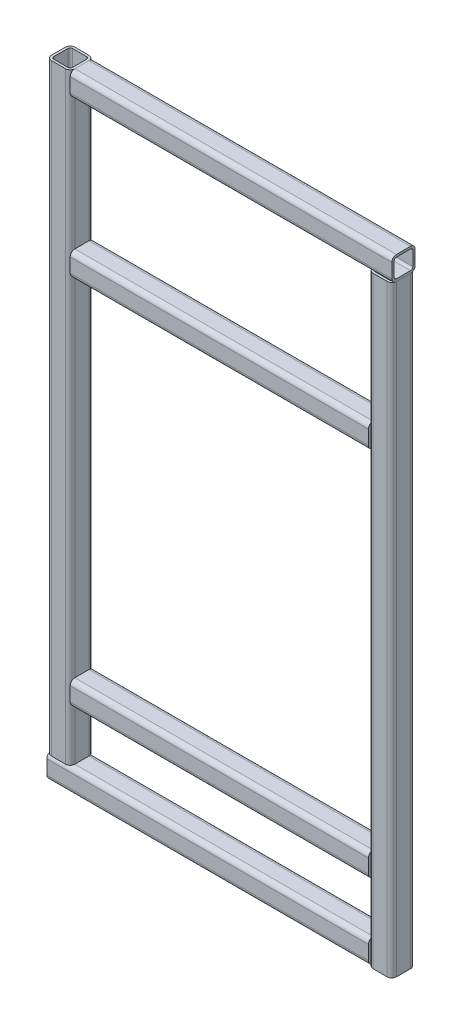
from build123d import *

# Parameters (mm, degrees)
SQUARE_TUBE_20_X_20_X_2_1_DEPTH      = 285
SQUARE_TUBE_20_X_20_X_2_1_DEPTH_BACK = 1
SQUARE_TUBE_20_X_20_X_2_1_2_DEPTH    = 526
SQUARE_TUBE_20_X_20_X_2_1_3_DEPTH    = 286
SQUARE_TUBE_20_X_20_X_2_1_4_DEPTH    = 526
SQUARE_TUBE_20_X_20_X_2_1_5_DEPTH    = 277
SQUARE_TUBE_20_X_20_X_2_1_6_DEPTH    = 277
SKETCH17_R                           = 2.5
CUT_EXTRUDE1_DEPTH                   = 5


with BuildPart() as part:
    # Sketch16 → Square tube 20 X 20 X 2(1) (new, two sides)
    with BuildSketch(Plane(origin=(-137.5, 257.5, 0), x_dir=(0, 1, 0), z_dir=(1, 0, 0))) as square_tube_20_x_20_x_2_1_sk:
        with BuildLine():
            Line((-6, -10), (6, -10))
            ThreePointArc((6, -10), (8.828427125, -8.828427125), (10, -6))
            Line((10, -6), (10, 6))
            ThreePointArc((10, 6), (8.828427125, 8.828427125), (6, 10))
            Line((6, 10), (-6, 10))
            ThreePointArc((-6, 10), (-8.828427125, 8.828427125), (-10, 6))
            Line((-10, 6), (-10, -6))
            ThreePointArc((-10, -6), (-8.828427125, -8.828427125), (-6, -10))
        make_face()
        with BuildLine():
            Line((-6, -8), (6, -8))
            ThreePointArc((6, -8), (7.414213562, -7.414213562), (8, -6))
            Line((8, -6), (8, 6))
            ThreePointArc((8, 6), (7.414213562, 7.414213562), (6, 8))
            Line((6, 8), (-6, 8))
            ThreePointArc((-6, 8), (-7.414213562, 7.414213562), (-8, 6))
            Line((-8, 6), (-8, -6))
            ThreePointArc((-8, -6), (-7.414213562, -7.414213562), (-6, -8))
        make_face(mode=Mode.SUBTRACT)
    extrude(amount=SQUARE_TUBE_20_X_20_X_2_1_DEPTH)
    extrude(square_tube_20_x_20_x_2_1_sk.sketch, amount=-SQUARE_TUBE_20_X_20_X_2_1_DEPTH_BACK)

    # Square tube 20 X 20 X 2(1) end butt 1
    split(bisect_by=Plane(origin=(-127.5, 257.5, 0), x_dir=(0, 1, 0), z_dir=(1, 0, 0)), keep=Keep.TOP)


with BuildPart() as body_2:
    # Sketch16 on segment 2 (carried to segment 2) → Square tube 20 X 20 X 2_1 2 (new body)
    with BuildSketch(Plane(origin=(137.5, 258.5, 0), x_dir=(1, 0, 0), z_dir=(0, -1, 0))):
        with BuildLine():
            Line((-6, -10), (6, -10))
            ThreePointArc((6, -10), (8.828427125, -8.828427125), (10, -6))
            Line((10, -6), (10, 6))
            ThreePointArc((10, 6), (8.828427125, 8.828427125), (6, 10))
            Line((6, 10), (-6, 10))
            ThreePointArc((-6, 10), (-8.828427125, 8.828427125), (-10, 6))
            Line((-10, 6), (-10, -6))
            ThreePointArc((-10, -6), (-8.828427125, -8.828427125), (-6, -10))
        make_face()
        with BuildLine():
            Line((-6, -8), (6, -8))
            ThreePointArc((6, -8), (7.414213562, -7.414213562), (8, -6))
            Line((8, -6), (8, 6))
            ThreePointArc((8, 6), (7.414213562, 7.414213562), (6, 8))
            Line((6, 8), (-6, 8))
            ThreePointArc((-6, 8), (-7.414213562, 7.414213562), (-8, 6))
            Line((-8, 6), (-8, -6))
            ThreePointArc((-8, -6), (-7.414213562, -7.414213562), (-6, -8))
        make_face(mode=Mode.SUBTRACT)
    extrude(amount=SQUARE_TUBE_20_X_20_X_2_1_2_DEPTH)

    # Square tube 20 X 20 X 2_1 2 end butt 1
    split(bisect_by=Plane(origin=(137.5, 247.5, 0), x_dir=(1, 0, 0), z_dir=(0, -1, 0)), keep=Keep.TOP)


with BuildPart() as body_3:
    # Sketch16 on segment 3 (carried to segment 3) → Square tube 20 X 20 X 2_1 3 (new body)
    with BuildSketch(Plane(origin=(138.5, -257.5, 0), x_dir=(0, -1, 0), z_dir=(-1, 0, 0))):
        with BuildLine():
            Line((-6, -10), (6, -10))
            ThreePointArc((6, -10), (8.828427125, -8.828427125), (10, -6))
            Line((10, -6), (10, 6))
            ThreePointArc((10, 6), (8.828427125, 8.828427125), (6, 10))
            Line((6, 10), (-6, 10))
            ThreePointArc((-6, 10), (-8.828427125, 8.828427125), (-10, 6))
            Line((-10, 6), (-10, -6))
            ThreePointArc((-10, -6), (-8.828427125, -8.828427125), (-6, -10))
        make_face()
        with BuildLine():
            Line((-6, -8), (6, -8))
            ThreePointArc((6, -8), (7.414213562, -7.414213562), (8, -6))
            Line((8, -6), (8, 6))
            ThreePointArc((8, 6), (7.414213562, 7.414213562), (6, 8))
            Line((6, 8), (-6, 8))
            ThreePointArc((-6, 8), (-7.414213562, 7.414213562), (-8, 6))
            Line((-8, 6), (-8, -6))
            ThreePointArc((-8, -6), (-7.414213562, -7.414213562), (-6, -8))
        make_face(mode=Mode.SUBTRACT)
    extrude(amount=SQUARE_TUBE_20_X_20_X_2_1_3_DEPTH)

    # Square tube 20 X 20 X 2_1 3 end butt 1
    split(bisect_by=Plane(origin=(127.5, -257.5, 0), x_dir=(0, -1, 0), z_dir=(-1, 0, 0)), keep=Keep.TOP)

    # Sketch17 → Cut-Extrude1 (cut)
    with BuildSketch(Plane(origin=(0, 0, -10), x_dir=(-1, 0, 0), z_dir=(0, 0, -1))):
        with Locations((35.5, -257.5)):
            Circle(SKETCH17_R)
        with Locations(Location((-35.5, -257.5, 0), (0, 0, 180))):
            Circle(SKETCH17_R)
    extrude(amount=-CUT_EXTRUDE1_DEPTH, mode=Mode.SUBTRACT)


with BuildPart() as body_4:
    # Sketch16 on segment 4 (carried to segment 4) → Square tube 20 X 20 X 2_1 4 (new body)
    with BuildSketch(Plane(origin=(-137.5, -258.5, 0), x_dir=(-1, 0, 0), z_dir=(0, 1, 0))):
        with BuildLine():
            Line((-6, -10), (6, -10))
            ThreePointArc((6, -10), (8.828427125, -8.828427125), (10, -6))
            Line((10, -6), (10, 6))
            ThreePointArc((10, 6), (8.828427125, 8.828427125), (6, 10))
            Line((6, 10), (-6, 10))
            ThreePointArc((-6, 10), (-8.828427125, 8.828427125), (-10, 6))
            Line((-10, 6), (-10, -6))
            ThreePointArc((-10, -6), (-8.828427125, -8.828427125), (-6, -10))
        make_face()
        with BuildLine():
            Line((-6, -8), (6, -8))
            ThreePointArc((6, -8), (7.414213562, -7.414213562), (8, -6))
            Line((8, -6), (8, 6))
            ThreePointArc((8, 6), (7.414213562, 7.414213562), (6, 8))
            Line((6, 8), (-6, 8))
            ThreePointArc((-6, 8), (-7.414213562, 7.414213562), (-8, 6))
            Line((-8, 6), (-8, -6))
            ThreePointArc((-8, -6), (-7.414213562, -7.414213562), (-6, -8))
        make_face(mode=Mode.SUBTRACT)
    extrude(amount=SQUARE_TUBE_20_X_20_X_2_1_4_DEPTH)

    # Square tube 20 X 20 X 2_1 4 end butt 1
    split(bisect_by=Plane(origin=(-137.5, -247.5, 0), x_dir=(-1, 0, 0), z_dir=(0, 1, 0)), keep=Keep.TOP)


with BuildPart() as body_5:
    # Sketch16 on segment 5 (carried to segment 5) → Square tube 20 X 20 X 2_1 5 (new body)
    with BuildSketch(Plane(origin=(138.5, 124.05, 0), x_dir=(0, -1, 0), z_dir=(-1, 0, 0))):
        with BuildLine():
            Line((-6, -10), (6, -10))
            ThreePointArc((6, -10), (8.828427125, -8.828427125), (10, -6))
            Line((10, -6), (10, 6))
            ThreePointArc((10, 6), (8.828427125, 8.828427125), (6, 10))
            Line((6, 10), (-6, 10))
            ThreePointArc((-6, 10), (-8.828427125, 8.828427125), (-10, 6))
            Line((-10, 6), (-10, -6))
            ThreePointArc((-10, -6), (-8.828427125, -8.828427125), (-6, -10))
        make_face()
        with BuildLine():
            Line((-6, -8), (6, -8))
            ThreePointArc((6, -8), (7.414213562, -7.414213562), (8, -6))
            Line((8, -6), (8, 6))
            ThreePointArc((8, 6), (7.414213562, 7.414213562), (6, 8))
            Line((6, 8), (-6, 8))
            ThreePointArc((-6, 8), (-7.414213562, 7.414213562), (-8, 6))
            Line((-8, 6), (-8, -6))
            ThreePointArc((-8, -6), (-7.414213562, -7.414213562), (-6, -8))
        make_face(mode=Mode.SUBTRACT)
    extrude(amount=SQUARE_TUBE_20_X_20_X_2_1_5_DEPTH)

    # Square tube 20 X 20 X 2_1 5 end butt 1
    split(bisect_by=Plane(origin=(127.5, 124.05, 0), x_dir=(0, -1, 0), z_dir=(-1, 0, 0)), keep=Keep.TOP)

    # Square tube 20 X 20 X 2_1 5 end butt 2
    split(bisect_by=Plane(origin=(-127.5, 124.05, 0), x_dir=(0, 1, 0), z_dir=(1, 0, 0)), keep=Keep.TOP)


with BuildPart() as body_6:
    # Sketch16 on segment 6 (carried to segment 6) → Square tube 20 X 20 X 2_1 6 (new body)
    with BuildSketch(Plane(origin=(-138.5, -193.48, 0), x_dir=(0, 1, 0), z_dir=(1, 0, 0))):
        with BuildLine():
            Line((-6, -10), (6, -10))
            ThreePointArc((6, -10), (8.828427125, -8.828427125), (10, -6))
            Line((10, -6), (10, 6))
            ThreePointArc((10, 6), (8.828427125, 8.828427125), (6, 10))
            Line((6, 10), (-6, 10))
            ThreePointArc((-6, 10), (-8.828427125, 8.828427125), (-10, 6))
            Line((-10, 6), (-10, -6))
            ThreePointArc((-10, -6), (-8.828427125, -8.828427125), (-6, -10))
        make_face()
        with BuildLine():
            Line((-6, -8), (6, -8))
            ThreePointArc((6, -8), (7.414213562, -7.414213562), (8, -6))
            Line((8, -6), (8, 6))
            ThreePointArc((8, 6), (7.414213562, 7.414213562), (6, 8))
            Line((6, 8), (-6, 8))
            ThreePointArc((-6, 8), (-7.414213562, 7.414213562), (-8, 6))
            Line((-8, 6), (-8, -6))
            ThreePointArc((-8, -6), (-7.414213562, -7.414213562), (-6, -8))
        make_face(mode=Mode.SUBTRACT)
    extrude(amount=SQUARE_TUBE_20_X_20_X_2_1_6_DEPTH)

    # Square tube 20 X 20 X 2_1 6 end butt 1
    split(bisect_by=Plane(origin=(-127.5, -193.48, 0), x_dir=(0, 1, 0), z_dir=(1, 0, 0)), keep=Keep.TOP)

    # Square tube 20 X 20 X 2_1 6 end butt 2
    split(bisect_by=Plane(origin=(127.5, -193.48, 0), x_dir=(0, -1, 0), z_dir=(-1, 0, 0)), keep=Keep.TOP)


solid = Compound([part.part, body_2.part, body_3.part, body_4.part, body_5.part, body_6.part])
